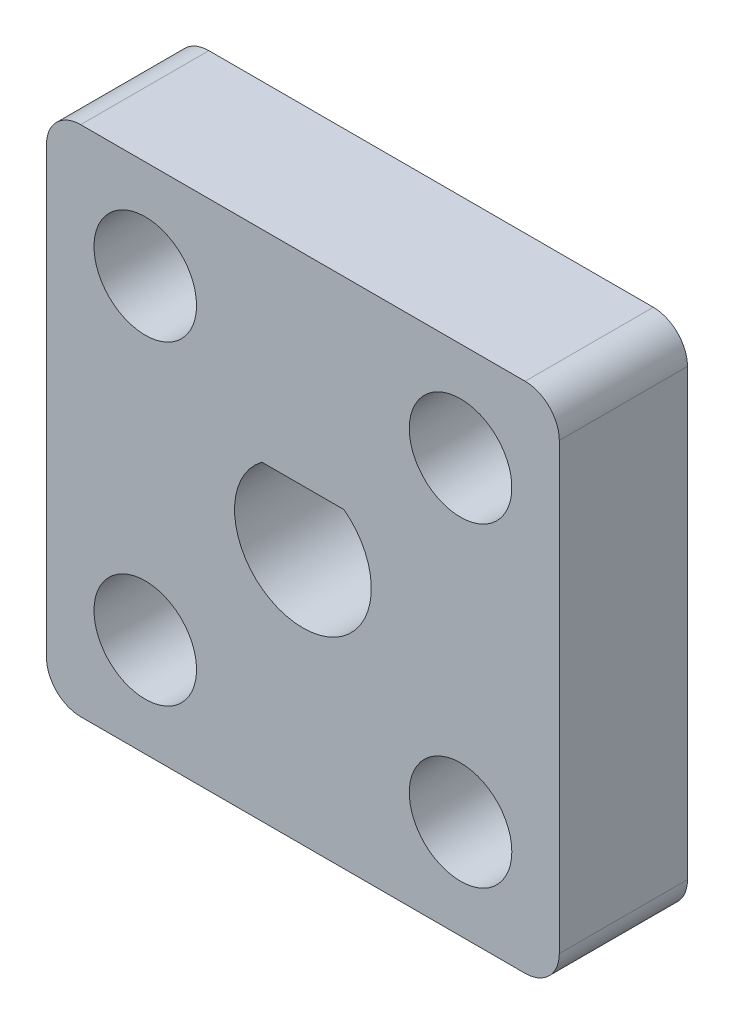
from build123d import *

# Parameters (mm, degrees)
SKETCH2_R           = 1.905
BOSS_EXTRUDE1_DEPTH = 4.7625


with BuildPart() as part:
    # Sketch2 → Boss-Extrude1 (new body)
    with BuildSketch(Plane.XY):
        with BuildLine():
            Line((-19.404343504, -3.787653884), (-2.894343504, -3.787653884))
            ThreePointArc((-2.894343504, -3.787653884), (-1.996317892, -3.415679496), (-1.624343504, -2.517653884))
            Line((-1.624343504, -2.517653884), (-1.624343504, 13.992346116))
            ThreePointArc((-1.624343504, 13.992346116), (-1.996317892, 14.890371728), (-2.894343504, 15.262346116))
            Line((-2.894343504, 15.262346116), (-19.404343504, 15.262346116))
            ThreePointArc((-19.404343504, 15.262346116), (-20.302369116, 14.890371728), (-20.674343504, 13.992346116))
            Line((-20.674343504, 13.992346116), (-20.674343504, -2.517653884))
            ThreePointArc((-20.674343504, -2.517653884), (-20.302369116, -3.415679496), (-19.404343504, -3.787653884))
        make_face()
        with Locations((-17.005652309, 11.593654921)):
            Circle(SKETCH2_R, mode=Mode.SUBTRACT)
        with Locations((-5.2930347, 11.593654921)):
            Circle(SKETCH2_R, mode=Mode.SUBTRACT)
        with Locations((-5.2930347, -0.118962689)):
            Circle(SKETCH2_R, mode=Mode.SUBTRACT)
        with Locations((-17.005652309, -0.118962689)):
            Circle(SKETCH2_R, mode=Mode.SUBTRACT)
        with BuildLine():
            Line((-12.673343504, 7.769346116), (-9.625343504, 7.769346116))
            ThreePointArc((-9.625343504, 7.769346116), (-11.149343504, 3.197346116), (-12.673343504, 7.769346116))
        make_face(mode=Mode.SUBTRACT)
    extrude(amount=BOSS_EXTRUDE1_DEPTH)


solid = part.part
